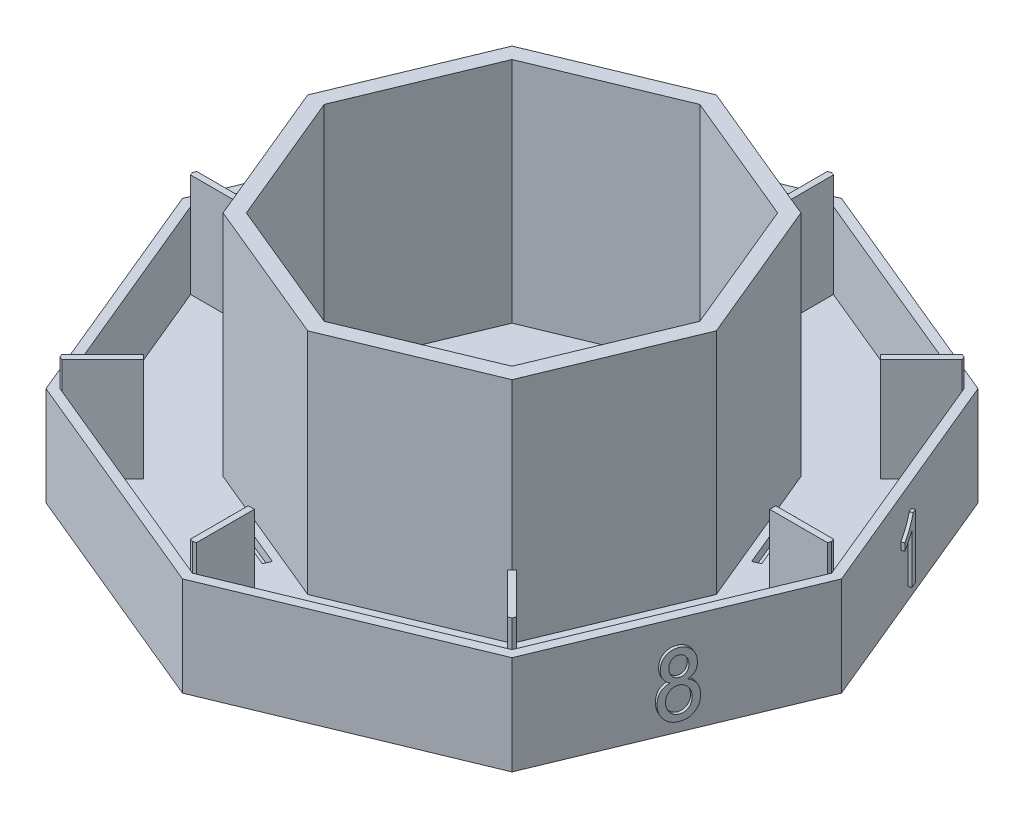
from build123d import *

# Parameters (mm, degrees)
SALIENTE_EXTRUIR1_DEPTH = 7.5
SALIENTE_EXTRUIR2_DEPTH = 75
SALIENTE_EXTRUIR3_DEPTH = 25
SALIENTE_EXTRUIR4_DEPTH = 34
CROQUIS7_R              = 3.2
CORTAR_EXTRUIR2_DEPTH   = 5
CROQUIS2_R              = 4.25
CROQUIS2_R_2            = 1.5
CORTAR_EXTRUIR3_DEPTH   = 7.5
CORTAR_EXTRUIR4_DEPTH   = 3
MATRIZC1_COUNT          = 8
SALIENTE_EXTRUIR6_DEPTH = 1
SALIENTE_EXTRUIR7_DEPTH = 1


with BuildPart() as part:
    # Croquis1 → Saliente-Extruir1 (new body)
    with BuildSketch(Plane(origin=(0, 0, 0), x_dir=(1, 0, 0), z_dir=(0, 1, 0))):
        Polygon((76.536686473, -76.536686473), (108.239220029, 0), (76.536686473, 76.536686473), (0, 108.239220029), (-76.536686473, 76.536686473), (-108.239220029, 0), (-76.536686473, -76.536686473), (0, -108.239220029), align=None)
    extrude(amount=SALIENTE_EXTRUIR1_DEPTH)

    # Croquis3 → Saliente-Extruir2 (add)
    with BuildSketch(Plane(origin=(0, 7.5, 0), x_dir=(1, 0, 0), z_dir=(0, 1, 0))):
        Polygon((0, 67.108316418), (-47.452745613, 47.452745613), (-67.108316418, 0), (-47.452745613, -47.452745613), (0, -67.108316418), (47.452745613, -47.452745613), (67.108316418, 0), (47.452745613, 47.452745613), align=None)
        Polygon((0, 61.696355417), (-43.62591129, 43.62591129), (-61.696355417, 0), (-43.62591129, -43.62591129), (0, -61.696355417), (43.62591129, -43.62591129), (61.696355417, 0), (43.62591129, 43.62591129), align=None, mode=Mode.SUBTRACT)
    extrude(amount=SALIENTE_EXTRUIR2_DEPTH)

    # Croquis4 → Saliente-Extruir3 (add)
    with BuildSketch(Plane(origin=(0, 7.5, 0), x_dir=(1, 0, 0), z_dir=(0, 1, 0))):
        Polygon((76.536686473, 76.536686473), (0, 108.239220029), (-76.536686473, 76.536686473), (-108.239220029, 0), (-76.536686473, -76.536686473), (0, -108.239220029), (76.536686473, -76.536686473), (108.239220029, 0), align=None)
        Polygon((-74.240585879, 74.240585879), (0, 104.992043428), (74.240585879, 74.240585879), (104.992043428, 0), (74.240585879, -74.240585879), (0, -104.992043428), (-74.240585879, -74.240585879), (-104.992043428, 0), align=None, mode=Mode.SUBTRACT)
        Polygon((76.536686473, 76.536686473), (0, 108.239220029), (-76.536686473, 76.536686473), (-108.239220029, 0), (-76.536686473, -76.536686473), (0, -108.239220029), (76.536686473, -76.536686473), (108.239220029, 0), align=None)
        Polygon((-74.240585879, 74.240585879), (0, 104.992043428), (74.240585879, 74.240585879), (104.992043428, 0), (74.240585879, -74.240585879), (0, -104.992043428), (-74.240585879, -74.240585879), (-104.992043428, 0), align=None, mode=Mode.SUBTRACT)
        Polygon((76.536686473, 76.536686473), (0, 108.239220029), (-76.536686473, 76.536686473), (-108.239220029, 0), (-76.536686473, -76.536686473), (0, -108.239220029), (76.536686473, -76.536686473), (108.239220029, 0), align=None)
        Polygon((-74.240585879, 74.240585879), (0, 104.992043428), (74.240585879, 74.240585879), (104.992043428, 0), (74.240585879, -74.240585879), (0, -104.992043428), (-74.240585879, -74.240585879), (-104.992043428, 0), align=None, mode=Mode.SUBTRACT)
        Polygon((76.536686473, 76.536686473), (0, 108.239220029), (-76.536686473, 76.536686473), (-108.239220029, 0), (-76.536686473, -76.536686473), (0, -108.239220029), (76.536686473, -76.536686473), (108.239220029, 0), align=None)
        Polygon((-74.240585879, 74.240585879), (0, 104.992043428), (74.240585879, 74.240585879), (104.992043428, 0), (74.240585879, -74.240585879), (0, -104.992043428), (-74.240585879, -74.240585879), (-104.992043428, 0), align=None, mode=Mode.SUBTRACT)
        Polygon((76.536686473, 76.536686473), (0, 108.239220029), (-76.536686473, 76.536686473), (-108.239220029, 0), (-76.536686473, -76.536686473), (0, -108.239220029), (76.536686473, -76.536686473), (108.239220029, 0), align=None)
        Polygon((-74.240585879, 74.240585879), (0, 104.992043428), (74.240585879, 74.240585879), (104.992043428, 0), (74.240585879, -74.240585879), (0, -104.992043428), (-74.240585879, -74.240585879), (-104.992043428, 0), align=None, mode=Mode.SUBTRACT)
        Polygon((76.536686473, 76.536686473), (0, 108.239220029), (-76.536686473, 76.536686473), (-108.239220029, 0), (-76.536686473, -76.536686473), (0, -108.239220029), (76.536686473, -76.536686473), (108.239220029, 0), align=None)
        Polygon((-74.240585879, 74.240585879), (0, 104.992043428), (74.240585879, 74.240585879), (104.992043428, 0), (74.240585879, -74.240585879), (0, -104.992043428), (-74.240585879, -74.240585879), (-104.992043428, 0), align=None, mode=Mode.SUBTRACT)
        Polygon((76.536686473, 76.536686473), (0, 108.239220029), (-76.536686473, 76.536686473), (-108.239220029, 0), (-76.536686473, -76.536686473), (0, -108.239220029), (76.536686473, -76.536686473), (108.239220029, 0), align=None)
        Polygon((-74.240585879, 74.240585879), (0, 104.992043428), (74.240585879, 74.240585879), (104.992043428, 0), (74.240585879, -74.240585879), (0, -104.992043428), (-74.240585879, -74.240585879), (-104.992043428, 0), align=None, mode=Mode.SUBTRACT)
        Polygon((76.536686473, 76.536686473), (0, 108.239220029), (-76.536686473, 76.536686473), (-108.239220029, 0), (-76.536686473, -76.536686473), (0, -108.239220029), (76.536686473, -76.536686473), (108.239220029, 0), align=None)
        Polygon((-74.240585879, 74.240585879), (0, 104.992043428), (74.240585879, 74.240585879), (104.992043428, 0), (74.240585879, -74.240585879), (0, -104.992043428), (-74.240585879, -74.240585879), (-104.992043428, 0), align=None, mode=Mode.SUBTRACT)
        Polygon((76.536686473, 76.536686473), (0, 108.239220029), (-76.536686473, 76.536686473), (-108.239220029, 0), (-76.536686473, -76.536686473), (0, -108.239220029), (76.536686473, -76.536686473), (108.239220029, 0), align=None)
        Polygon((-74.240585879, 74.240585879), (0, 104.992043428), (74.240585879, 74.240585879), (104.992043428, 0), (74.240585879, -74.240585879), (0, -104.992043428), (-74.240585879, -74.240585879), (-104.992043428, 0), align=None, mode=Mode.SUBTRACT)
    extrude(amount=SALIENTE_EXTRUIR3_DEPTH)

    # Croquis5 → Saliente-Extruir4 (add)
    with BuildSketch(Plane(origin=(0, 7.5, 0), x_dir=(1, 0, 0), z_dir=(0, 1, 0))):
        Polygon((-74.240585879, -74.240585879), (-73.240585879, -74.654799441), (-59.846665746, -61.260879308), (-61.260879308, -59.846665746), (-74.654799441, -73.240585879), align=None)
        Polygon((-85.635966361, -1), (-85.635966361, 1), (-104.577829866, 1), (-104.992043428, 0), (-104.577829866, -1), align=None)
        Polygon((-61.260879308, 59.846665746), (-59.846665746, 61.260879308), (-73.240585879, 74.654799441), (-74.240585879, 74.240585879), (-74.654799441, 73.240585879), align=None)
        Polygon((-1, 85.635966361), (1, 85.635966361), (1, 104.577829866), (0, 104.992043428), (-1, 104.577829866), align=None)
        Polygon((59.846665746, 61.260879308), (61.260879308, 59.846665746), (74.654799441, 73.240585879), (74.240585879, 74.240585879), (73.240585879, 74.654799441), align=None)
        Polygon((85.635966361, 1), (85.635966361, -1), (104.577829866, -1), (104.992043428, 0), (104.577829866, 1), align=None)
        Polygon((61.260879308, -59.846665746), (59.846665746, -61.260879308), (73.240585879, -74.654799441), (74.240585879, -74.240585879), (74.654799441, -73.240585879), align=None)
        Polygon((1, -85.635966361), (-1, -85.635966361), (-1, -104.577829866), (0, -104.992043428), (1, -104.577829866), align=None)
    extrude(amount=SALIENTE_EXTRUIR4_DEPTH)

    # Croquis7 → Cortar-Extruir2 (cut)
    with BuildSketch(Plane.XZ):
        with Locations((-83.149157926, 34.441508913)):
            Circle(CROQUIS7_R)
        with Locations((-34.441508913, 83.149157926)):
            Circle(CROQUIS7_R)
        with Locations((34.441508913, 83.149157926)):
            Circle(CROQUIS7_R)
        with Locations((83.149157926, 34.441508913)):
            Circle(CROQUIS7_R)
        with Locations((83.149157926, -34.441508913)):
            Circle(CROQUIS7_R)
        with Locations((34.441508913, -83.149157926)):
            Circle(CROQUIS7_R)
        with Locations((-34.441508913, -83.149157926)):
            Circle(CROQUIS7_R)
        with Locations((-83.149157926, -34.441508913)):
            Circle(CROQUIS7_R)
        with Locations((-46.193976626, 19.134171618)):
            Circle(CROQUIS7_R)
    extrude(amount=-CORTAR_EXTRUIR2_DEPTH, mode=Mode.SUBTRACT)

    # Croquis2 → Cortar-Extruir3 (cut)
    with BuildSketch(Plane(origin=(0, 7.5, 0), x_dir=(1, 0, 0), z_dir=(0, 1, 0))):
        Circle(CROQUIS2_R)
        with Locations((0, 10)):
            Circle(CROQUIS2_R_2)
        with Locations((10, 0)):
            Circle(CROQUIS2_R_2)
        with Locations((0, -10)):
            Circle(CROQUIS2_R_2)
        with Locations((-10, 0)):
            Circle(CROQUIS2_R_2)
    extrude(amount=-CORTAR_EXTRUIR3_DEPTH, mode=Mode.SUBTRACT)

    # Croquis8 → Cortar-Extruir4 (cut)
    with BuildSketch(Plane(origin=(0, 7.5, 0), x_dir=(1, 0, 0), z_dir=(0, 1, 0))):
        Polygon((34.152846596, 55.667724665), (35.109555177, 57.977423497), (16.17002476, 65.82243386), (15.213316179, 63.512735029), align=None)
    cortar_extruir4 = extrude(amount=-CORTAR_EXTRUIR4_DEPTH, mode=Mode.SUBTRACT)

    # MatrizC1: Cortar-Extruir4 ×8 about axis
    matrizc1_axis = Axis((0, 0, 0), (0, 1, 0))
    for i in range(1, MATRIZC1_COUNT):
        add(cortar_extruir4.rotate(matrizc1_axis, i * 360 / MATRIZC1_COUNT), mode=Mode.SUBTRACT)

    # Croquis10 → Saliente-Extruir6 (add)
    with BuildSketch(Plane(origin=(92.387953251, 0, -38.268343237), x_dir=(-0.382683432, 0, -0.923879533), z_dir=(0.923879533, 0, -0.382683432))):
        with BuildLine():
            Line((1.014226721, 4), (-1.120479718, 4))
            Line((-1.120479718, 4), (-1.120479718, 20.2771366))
            add(Edge.make_bspline(
                [(-1.120479718, 20.2771366), (-1.251579834, 20.126229123), (-1.52328469, 19.813473531), (-1.994950385, 19.3686915), (-2.520569692, 18.910030474), (-3.102500052, 18.464967255), (-3.695440767, 18.038668703), (-4.281079913, 17.663731717), (-4.837468001, 17.337508273), (-5.210725877, 17.160190749), (-5.389892597, 17.075076941)],
                knots=[0, 0, 0, 0, 0.000599357, 0.001242168, 0.00194268, 0.002691586, 0.003438959, 0.004132877, 0.00477724, 0.005372056, 0.005372056, 0.005372056, 0.005372056], degree=3))
            Line((-5.389892597, 17.075076941), (-5.389892597, 19.476621686))
            add(Edge.make_bspline(
                [(-5.389892597, 19.476621686), (-5.101957226, 19.64991215), (-4.528552, 19.995009238), (-3.725136237, 20.592828835), (-2.966159747, 21.238076805), (-2.274308147, 21.937513903), (-1.654831029, 22.658528842), (-1.123119576, 23.378102638), (-0.687149863, 24.088589923), (-0.473292761, 24.577323215), (-0.369996985, 24.813387784)],
                knots=[0, 0, 0, 0, 0.001007646, 0.002006664, 0.003000212, 0.003993751, 0.004954739, 0.005849528, 0.006676111, 0.007448375, 0.007448375, 0.007448375, 0.007448375], degree=3))
            Line((-0.369996985, 24.813387784), (1.014226721, 24.813387784))
            Line((1.014226721, 24.813387784), (1.014226721, 4))
        make_face()
    extrude(amount=SALIENTE_EXTRUIR6_DEPTH)

    # Croquis11 → Saliente-Extruir7 (add)
    with BuildSketch(Plane(origin=(92.387953251, 0, 38.268343237), x_dir=(0.382683432, 0, -0.923879533), z_dir=(0.923879533, 0, 0.382683432))):
        with BuildLine():
            add(Edge.make_bspline(
                [(-2.057961449, 15.273918383), (-2.254374579, 15.37262195), (-2.63757996, 15.5651943), (-3.148349153, 15.942387663), (-3.58388546, 16.380431847), (-3.942653351, 16.882482125), (-4.220232247, 17.449027952), (-4.413223803, 18.078080191), (-4.538711742, 18.768419206), (-4.549693636, 19.250886891), (-4.555401209, 19.501637777)],
                knots=[0, 0, 0, 0, 0.00065852, 0.001284783, 0.001895062, 0.002504786, 0.00312757, 0.003778976, 0.004473357, 0.005224778, 0.005224778, 0.005224778, 0.005224778], degree=3))
            add(Edge.make_bspline(
                [(-4.555401209, 19.501637777), (-4.551578929, 19.693597652), (-4.544106938, 20.068850719), (-4.480334915, 20.618441022), (-4.3755957, 21.139441692), (-4.236929002, 21.635682236), (-4.045092613, 22.099612933), (-3.821409944, 22.542202313), (-3.54840151, 22.95360382), (-3.241500931, 23.337558662), (-2.90090104, 23.681551392), (-2.536858156, 23.983924609), (-2.15054289, 24.241453593), (-1.741127442, 24.44906783), (-1.312377156, 24.613412861), (-0.862586089, 24.731830613), (-0.390745429, 24.797052537), (-0.06936877, 24.807895404), (0.093422384, 24.813387784)],
                knots=[0, 0, 0, 0, 0.000575748, 0.001125501, 0.001656991, 0.00216899, 0.002668372, 0.003160656, 0.003654438, 0.004146703, 0.004633161, 0.005104002, 0.005564239, 0.006022943, 0.006478243, 0.006939385, 0.00741522, 0.007903675, 0.007903675, 0.007903675, 0.007903675], degree=3))
            add(Edge.make_bspline(
                [(0.093422384, 24.813387784), (0.257666993, 24.808365448), (0.582136201, 24.798443702), (1.057370377, 24.726391381), (1.511537725, 24.609249534), (1.94464297, 24.446440313), (2.355994632, 24.232027662), (2.742944651, 23.968049089), (3.110286335, 23.659391648), (3.453119972, 23.308067365), (3.76428988, 22.918109896), (4.035526726, 22.497968733), (4.272771437, 22.055248164), (4.459267785, 21.580160766), (4.605725733, 21.077732718), (4.708388116, 20.547354541), (4.772596927, 19.991031918), (4.780110472, 19.611609111), (4.783939463, 19.418250806)],
                knots=[0, 0, 0, 0, 0.000492619, 0.00097318, 0.001438357, 0.001897553, 0.002358167, 0.00282651, 0.00330002, 0.003795349, 0.004296729, 0.004794001, 0.005293836, 0.005800957, 0.006322125, 0.006861794, 0.007419833, 0.007999747, 0.007999747, 0.007999747, 0.007999747], degree=3))
            add(Edge.make_bspline(
                [(4.783939463, 19.418250806), (4.777846517, 19.177252976), (4.766109842, 18.713025493), (4.645058904, 18.046333878), (4.456610803, 17.435112266), (4.182234371, 16.882807212), (3.831505545, 16.386545421), (3.400784142, 15.951185236), (2.894394908, 15.567011532), (2.509664227, 15.373554735), (2.311515794, 15.273918383)],
                knots=[0, 0, 0, 0, 0.000722273, 0.001391294, 0.002025542, 0.002635266, 0.00323336, 0.003840713, 0.004466115, 0.005130286, 0.005130286, 0.005130286, 0.005130286], degree=3))
            add(Edge.make_bspline(
                [(2.311515794, 15.273918383), (2.440326287, 15.221810551), (2.695400059, 15.118625312), (3.056619605, 14.92932324), (3.397390924, 14.721897179), (3.710196007, 14.485756974), (4.004388701, 14.231002166), (4.276103134, 13.95154188), (4.5220357, 13.646511841), (4.742581401, 13.318799939), (4.946118677, 12.973223495), (5.113511812, 12.601070149), (5.262353872, 12.212309997), (5.377289419, 11.801457371), (5.469410104, 11.371175931), (5.534600163, 10.921265885), (5.57898468, 10.450869409), (5.582601889, 10.13043998), (5.584454378, 9.966337724)],
                knots=[0, 0, 0, 0, 0.000416622, 0.000825005, 0.001221883, 0.001612135, 0.001999256, 0.00238846, 0.002779801, 0.003172982, 0.00357274, 0.003981293, 0.004395593, 0.00482054, 0.005259669, 0.005714874, 0.006183698, 0.00667584, 0.00667584, 0.00667584, 0.00667584], degree=3))
            add(Edge.make_bspline(
                [(5.584454378, 9.966337724), (5.579299321, 9.742434248), (5.569186828, 9.303210738), (5.500218969, 8.659367809), (5.372331662, 8.048012034), (5.20411015, 7.466034581), (4.980948953, 6.918308382), (4.713812611, 6.399462262), (4.390919809, 5.916497765), (4.024929249, 5.4671892), (3.624846935, 5.061363281), (3.195034685, 4.707684332), (2.743585432, 4.405414976), (2.266344829, 4.15632579), (1.762048724, 3.971111195), (1.238129374, 3.82981573), (0.68919023, 3.751814809), (0.316012674, 3.739437921), (0.126777172, 3.733161695)],
                knots=[0, 0, 0, 0, 0.000671731, 0.001317711, 0.001939154, 0.002543379, 0.003132571, 0.003710669, 0.004291167, 0.00487201, 0.005446912, 0.005997834, 0.006539015, 0.007074204, 0.007608548, 0.008147572, 0.008699472, 0.009267254, 0.009267254, 0.009267254, 0.009267254], degree=3))
            add(Edge.make_bspline(
                [(0.126777172, 3.733161695), (-0.065245427, 3.739368308), (-0.442596519, 3.751565166), (-0.996966493, 3.829986116), (-1.524092304, 3.970161618), (-2.030224158, 4.157546148), (-2.510328498, 4.403912837), (-2.962485443, 4.709227373), (-3.39632952, 5.059707452), (-3.795687141, 5.467745717), (-4.164670461, 5.915482139), (-4.479291781, 6.406452546), (-4.754855999, 6.926233403), (-4.974505135, 7.483251572), (-5.146209771, 8.073714972), (-5.264852644, 8.699260304), (-5.342473314, 9.357054606), (-5.351379436, 9.807675147), (-5.355916124, 10.037216649)],
                knots=[0, 0, 0, 0, 0.00057611, 0.001132136, 0.001675193, 0.002209536, 0.002748432, 0.003289613, 0.00384376, 0.004418661, 0.004999504, 0.005581199, 0.006164923, 0.006761854, 0.007374081, 0.008006971, 0.008669989, 0.009358386, 0.009358386, 0.009358386, 0.009358386], degree=3))
            add(Edge.make_bspline(
                [(-5.355916124, 10.037216649), (-5.353899967, 10.205466531), (-5.349944391, 10.535562326), (-5.307496259, 11.020289331), (-5.236741605, 11.482445574), (-5.141228236, 11.921294049), (-5.020737704, 12.33725884), (-4.870322864, 12.73062656), (-4.691301331, 13.101385765), (-4.48544959, 13.449468224), (-4.257725785, 13.773716569), (-4.00694743, 14.071310618), (-3.733785271, 14.339552176), (-3.440737543, 14.581953283), (-3.127338819, 14.801400562), (-2.789299862, 14.986869636), (-2.432388395, 15.14776156), (-2.183829954, 15.23150912), (-2.057961449, 15.273918383)],
                knots=[0, 0, 0, 0, 0.000504646, 0.000990084, 0.001458278, 0.00190644, 0.00233655, 0.002756228, 0.00316834, 0.003570201, 0.003968128, 0.004355698, 0.004736024, 0.005115045, 0.005495554, 0.005881888, 0.006270086, 0.006668341, 0.006668341, 0.006668341, 0.006668341], degree=3))
        make_face()
        with BuildLine():
            add(Edge.make_bspline(
                [(-2.42069477, 19.560008656), (-2.41267909, 19.321666533), (-2.397341693, 18.865616956), (-2.259691486, 18.217221268), (-2.025241685, 17.646044158), (-1.704318901, 17.157495386), (-1.311716059, 16.769768202), (-0.87383288, 16.478665317), (-0.386164641, 16.303683455), (-0.045536775, 16.284344868), (0.126777172, 16.274562027)],
                knots=[0, 0, 0, 0, 0.000714432, 0.001367012, 0.001976379, 0.002556877, 0.003108194, 0.003620498, 0.004124213, 0.0046399, 0.0046399, 0.0046399, 0.0046399], degree=3))
            add(Edge.make_bspline(
                [(0.126777172, 16.274562027), (0.296471973, 16.28413014), (0.63200213, 16.303048756), (1.109203177, 16.481264677), (1.546263526, 16.759973049), (1.929960072, 17.145614895), (2.251078418, 17.617103707), (2.48637286, 18.162687803), (2.625433413, 18.773460796), (2.641101748, 19.200699396), (2.649233024, 19.422420155)],
                knots=[0, 0, 0, 0, 0.000507394, 0.001003249, 0.001507533, 0.002052954, 0.002623073, 0.003209412, 0.003825361, 0.004489872, 0.004489872, 0.004489872, 0.004489872], degree=3))
            add(Edge.make_bspline(
                [(2.649233024, 19.422420155), (2.641417874, 19.651128951), (2.626336192, 20.092491394), (2.483090352, 20.721180296), (2.242971027, 21.285073891), (1.908663674, 21.768457195), (1.519155201, 22.170338309), (1.080310794, 22.462363042), (0.603393998, 22.645862465), (0.270125879, 22.66766623), (0.101761081, 22.678681345)],
                knots=[0, 0, 0, 0, 0.00068531, 0.001322511, 0.001921984, 0.00251293, 0.003076039, 0.003590628, 0.004083988, 0.004587703, 0.004587703, 0.004587703, 0.004587703], degree=3))
            add(Edge.make_bspline(
                [(0.101761081, 22.678681345), (-0.066495336, 22.669010975), (-0.399223756, 22.64988774), (-0.875785307, 22.472113972), (-1.310140053, 22.182825672), (-1.694362814, 21.791781459), (-2.022549479, 21.323830777), (-2.249716095, 20.78311497), (-2.398686939, 20.190604803), (-2.413191601, 19.774998907), (-2.42069477, 19.560008656)],
                knots=[0, 0, 0, 0, 0.000503249, 0.000995179, 0.001503994, 0.00205825, 0.002630728, 0.003207757, 0.003808433, 0.004452149, 0.004452149, 0.004452149, 0.004452149], degree=3))
        make_face(mode=Mode.SUBTRACT)
        with BuildLine():
            add(Edge.make_bspline(
                [(-3.221209685, 10.045555346), (-3.217863335, 9.892552504), (-3.211307384, 9.59279923), (-3.164324078, 9.155318424), (-3.09179548, 8.740308305), (-2.981200484, 8.350444581), (-2.844725774, 7.980863553), (-2.673481712, 7.634732339), (-2.471163307, 7.311770757), (-2.245133674, 7.01164249), (-1.989733329, 6.748731758), (-1.726368343, 6.510819603), (-1.448809973, 6.310945252), (-1.155739224, 6.149702815), (-0.85161045, 6.025775952), (-0.536518397, 5.932051578), (-0.208764596, 5.876307027), (0.013992209, 5.870704682), (0.126777172, 5.867868134)],
                knots=[0, 0, 0, 0, 0.000458931, 0.000899109, 0.001318641, 0.001721259, 0.002113111, 0.002499086, 0.002877395, 0.003255153, 0.003623781, 0.00397522, 0.004318856, 0.004647283, 0.004976345, 0.005302222, 0.005631917, 0.005970046, 0.005970046, 0.005970046, 0.005970046], degree=3))
            add(Edge.make_bspline(
                [(0.126777172, 5.867868134), (0.240999031, 5.87048507), (0.465238824, 5.875622626), (0.794708244, 5.933934822), (1.11120216, 6.019457245), (1.414193549, 6.142513797), (1.704645215, 6.297321011), (1.979679889, 6.489899218), (2.240425907, 6.719469123), (2.489267886, 6.977910653), (2.711310156, 7.271305928), (2.916535968, 7.582116923), (3.074768255, 7.924867108), (3.21706932, 8.283627405), (3.316925123, 8.670847735), (3.40045535, 9.079261845), (3.437824672, 9.51398042), (3.445716926, 9.81064522), (3.449747938, 9.962168376)],
                knots=[0, 0, 0, 0, 0.000342293, 0.000671988, 0.001000733, 0.001324361, 0.001650798, 0.001986216, 0.002329017, 0.00269175, 0.003060355, 0.003431614, 0.003806438, 0.004190494, 0.004587984, 0.005004188, 0.005439801, 0.005894565, 0.005894565, 0.005894565, 0.005894565], degree=3))
            add(Edge.make_bspline(
                [(3.449747938, 9.962168376), (3.446261678, 10.115144974), (3.439431623, 10.414846832), (3.394382902, 10.852949723), (3.314815473, 11.266900796), (3.205970853, 11.657366108), (3.068848887, 12.026771352), (2.898101739, 12.373921632), (2.692802368, 12.696028397), (2.458084784, 12.990911203), (2.207286054, 13.26043945), (1.939608797, 13.496013844), (1.657649194, 13.692794814), (1.365555047, 13.85795668), (1.059197213, 13.981731648), (0.742948346, 14.076290853), (0.412231428, 14.131311385), (0.186737516, 14.136983791), (0.072575642, 14.139855587)],
                knots=[0, 0, 0, 0, 0.000458931, 0.000899109, 0.001319407, 0.001722025, 0.002113877, 0.002499851, 0.002880383, 0.003257404, 0.003629061, 0.003983627, 0.004324852, 0.004658947, 0.004988008, 0.005313885, 0.005647694, 0.005989987, 0.005989987, 0.005989987, 0.005989987], degree=3))
            add(Edge.make_bspline(
                [(0.072575642, 14.139855587), (-0.04018368, 14.13694937), (-0.262889842, 14.131209425), (-0.589694413, 14.07669354), (-0.900458869, 13.980383278), (-1.204141899, 13.864332437), (-1.487856115, 13.694973055), (-1.76535538, 13.501713644), (-2.023052515, 13.264079775), (-2.268803797, 12.99908767), (-2.492221736, 12.704487026), (-2.689812818, 12.387258237), (-2.85247242, 12.046698241), (-2.98484412, 11.685876644), (-3.095303401, 11.306350873), (-3.16958985, 10.904150594), (-3.209902319, 10.481387092), (-3.217385505, 10.192954749), (-3.221209685, 10.045555346)],
                knots=[0, 0, 0, 0, 0.000338129, 0.000667824, 0.000989702, 0.00131333, 0.001640166, 0.001977986, 0.00232632, 0.002689245, 0.003061159, 0.003433727, 0.003808551, 0.004191133, 0.004585726, 0.004992959, 0.005416122, 0.005858388, 0.005858388, 0.005858388, 0.005858388], degree=3))
        make_face(mode=Mode.SUBTRACT)
    extrude(amount=SALIENTE_EXTRUIR7_DEPTH)


solid = part.part
